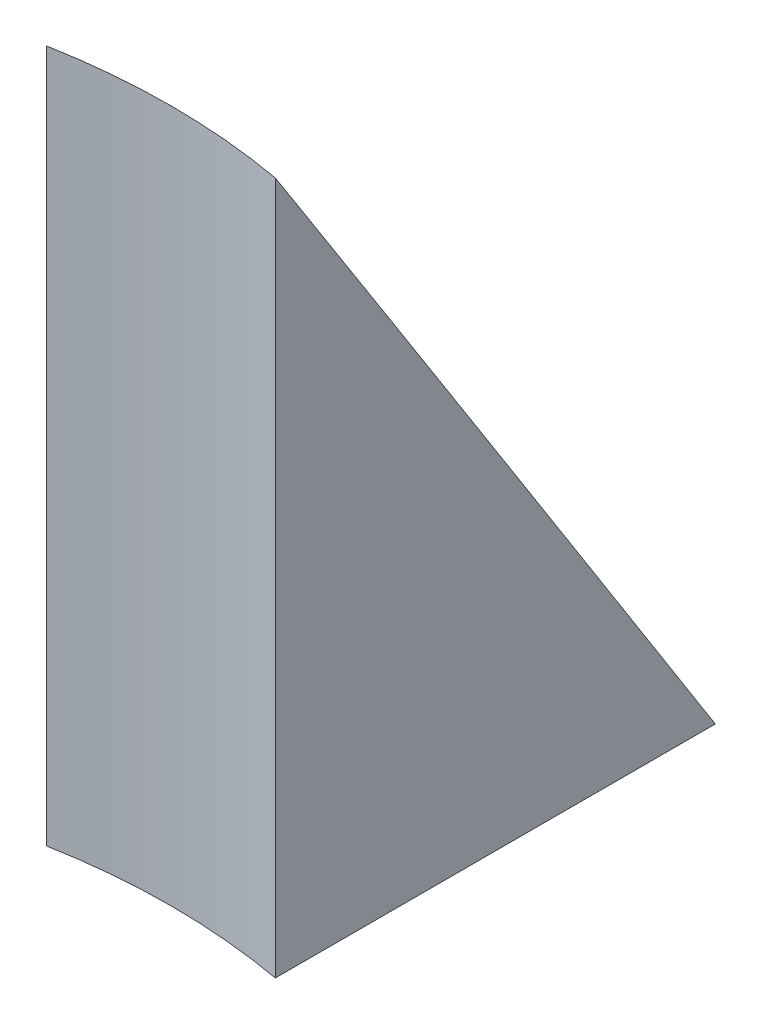
from build123d import *

# Parameters (mm, degrees)
SKETCH2_OUTSIDE_W   = 195.522
SKETCH2_OUTSIDE_H   = 195.522
SKETCH2_OUTSIDE_W_2 = 16
SKETCH2_OUTSIDE_H_2 = 72.429790915
CUT_EXTRUDE1_DEPTH  = 49.5


with BuildPart() as part:
    # Sketch1 → Revolve1 (revolve)
    with BuildSketch(Plane.XY):
        Polygon((44.5, 0), (44.5, 48.5), (75, 0), align=None)
    revolve(axis=Axis((0, 0, 0), (0, 1, 0)))

    # Sketch2 outside → Cut-Extrude1 (cut, through all)
    with BuildSketch(Plane.XZ):
        Rectangle(SKETCH2_OUTSIDE_W, SKETCH2_OUTSIDE_H)
        with Locations((0, -64.341797595)):
            Rectangle(SKETCH2_OUTSIDE_W_2, SKETCH2_OUTSIDE_H_2, mode=Mode.SUBTRACT)
    extrude(amount=-CUT_EXTRUDE1_DEPTH, mode=Mode.SUBTRACT)


solid = part.part
